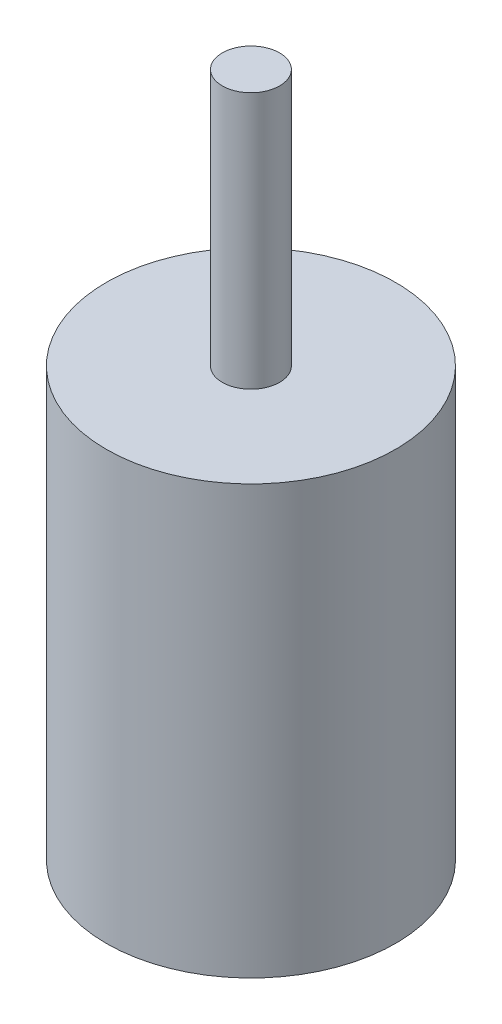
from build123d import *

# Parameters (mm, degrees)
SKETCH1_R           = 21.463
BOSS_EXTRUDE1_DEPTH = 63.5
SKETCH2_R           = 4.25
BOSS_EXTRUDE2_DEPTH = 38.1


with BuildPart() as part:
    # Sketch1 → Boss-Extrude1 (new body)
    with BuildSketch(Plane(origin=(0, 0, 0), x_dir=(1, 0, 0), z_dir=(0, 1, 0))):
        Circle(SKETCH1_R)
    extrude(amount=BOSS_EXTRUDE1_DEPTH)

    # Sketch2 → Boss-Extrude2 (add)
    with BuildSketch(Plane(origin=(0, 63.5, 0), x_dir=(1, 0, 0), z_dir=(0, 1, 0))):
        Circle(SKETCH2_R)
    extrude(amount=BOSS_EXTRUDE2_DEPTH)


solid = part.part
